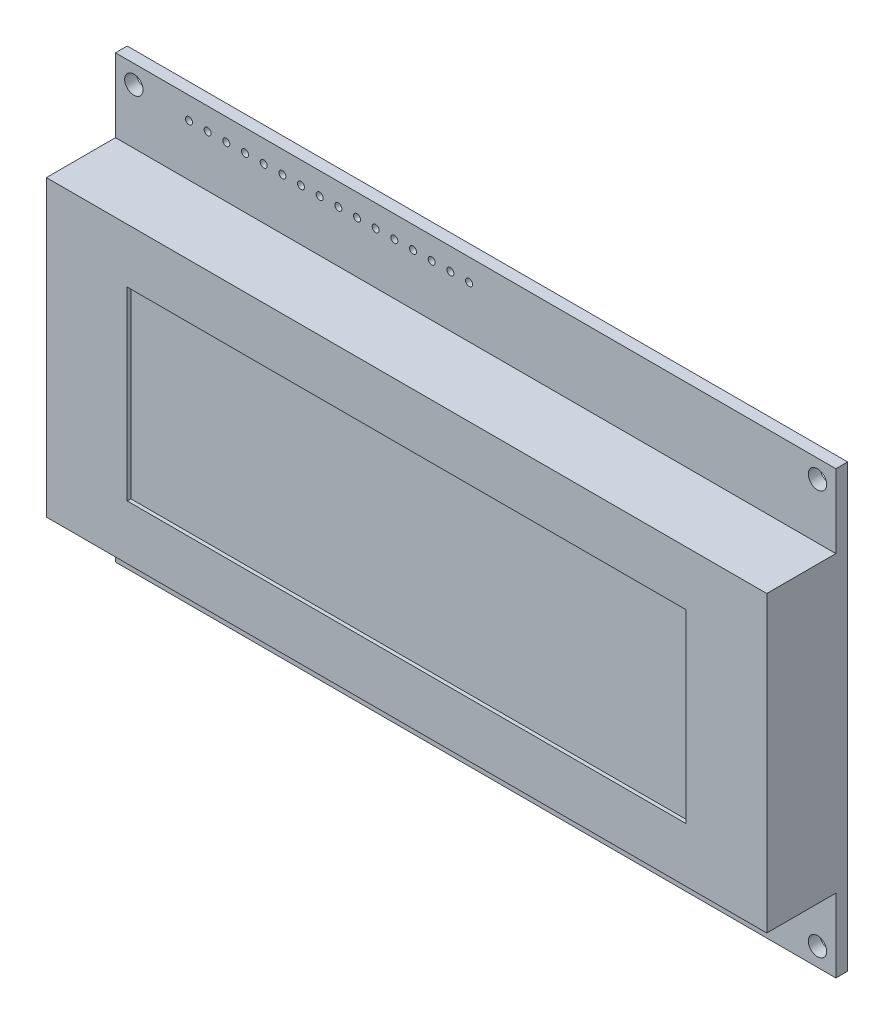
from build123d import *

# Parameters (mm, degrees)
SKETCH1_W                        = 98
SKETCH1_H                        = 60
BOSS_EXTRUDE1_DEPTH              = 11
SKETCH2_W                        = 9.4
SKETCH2_H                        = 10
CUT_EXTRUDE1_DEPTH               = 99
SKETCH3_W                        = 9.4
SKETCH3_H                        = 10
CUT_EXTRUDE2_DEPTH               = 99
SKETCH4_W                        = 3.935514966
SKETCH4_H                        = 1.073322306
BOSS_EXTRUDE2_DEPTH              = 3
SKETCH5_W                        = 3.015
SKETCH5_H                        = 1.118767377
BOSS_EXTRUDE3_DEPTH              = 3
SKETCH6_W                        = 76
SKETCH6_H                        = 25.2
CUT_EXTRUDE3_DEPTH               = 0.5
F_2_5_2_5_DIAMETER_HOLE1_D       = 2.5
F_2_5_2_5_DIAMETER_HOLE1_DEPTH   = 11
F_0_95_0_95_DIAMETER_HOLE1_D     = 0.95
F_0_95_0_95_DIAMETER_HOLE1_DEPTH = 11


with BuildPart() as part:
    # Sketch1 → Boss-Extrude1 (new body)
    with BuildSketch(Plane.XY.offset(11)):
        Rectangle(SKETCH1_W, SKETCH1_H)
    extrude(amount=-BOSS_EXTRUDE1_DEPTH)

    # Sketch2 → Cut-Extrude1 (cut, through all)
    with BuildSketch(Plane(origin=(49, 0, 0), x_dir=(0, 0, -1), z_dir=(1, 0, 0))):
        with Locations((-6.3, -25)):
            Rectangle(SKETCH2_W, SKETCH2_H)
    extrude(amount=-CUT_EXTRUDE1_DEPTH, mode=Mode.SUBTRACT)

    # Sketch3 → Cut-Extrude2 (cut, through all)
    with BuildSketch(Plane(origin=(49, 0, 0), x_dir=(0, 0, -1), z_dir=(1, 0, 0))):
        with Locations((-6.3, 25)):
            Rectangle(SKETCH3_W, SKETCH3_H)
    extrude(amount=-CUT_EXTRUDE2_DEPTH, mode=Mode.SUBTRACT)

    # Sketch4 → Boss-Extrude2 (add)
    with BuildSketch(Plane(origin=(0, 0, 0), x_dir=(-1, 0, 0), z_dir=(0, 0, -1))):
        with Locations((-34.644135617, 16.964786449)):
            Rectangle(SKETCH4_W, SKETCH4_H)
    extrude(amount=BOSS_EXTRUDE2_DEPTH)

    # Sketch5 → Boss-Extrude3 (add)
    with BuildSketch(Plane(origin=(0, 0, 0), x_dir=(-1, 0, 0), z_dir=(0, 0, -1))):
        with Locations((27.8075, -21.700286291)):
            Rectangle(SKETCH5_W, SKETCH5_H)
    extrude(amount=BOSS_EXTRUDE3_DEPTH)

    # Sketch6 → Cut-Extrude3 (cut)
    with BuildSketch(Plane.XY.offset(11)):
        Rectangle(SKETCH6_W, SKETCH6_H)
    extrude(amount=-CUT_EXTRUDE3_DEPTH, mode=Mode.SUBTRACT)

    # Ø2.5 (2.5) Diameter Hole1
    with Locations(Plane(origin=(0, 0, 0), x_dir=(-1, 0, 0), z_dir=(0, 0, -1))):
        with Locations((46.5, -27.5), (-46.5, -27.5), (-46.5, 27.5), (46.5, 27.5)):
            Hole(F_2_5_2_5_DIAMETER_HOLE1_D / 2, depth=F_2_5_2_5_DIAMETER_HOLE1_DEPTH)

    # Ø0.95 (0.95) Diameter Hole1
    with Locations(Plane(origin=(0, 0, 0), x_dir=(-1, 0, 0), z_dir=(0, 0, -1))):
        with Locations((0.9, 27), (3.44, 27), (5.98, 27), (8.52, 27), (11.06, 27), (13.6, 27), (16.14, 27), (18.68, 27), (21.22, 27), (23.76, 27), (26.3, 27), (28.84, 27), (31.38, 27), (33.92, 27), (36.46, 27), (39, 27)):
            Hole(F_0_95_0_95_DIAMETER_HOLE1_D / 2, depth=F_0_95_0_95_DIAMETER_HOLE1_DEPTH)


solid = part.part
